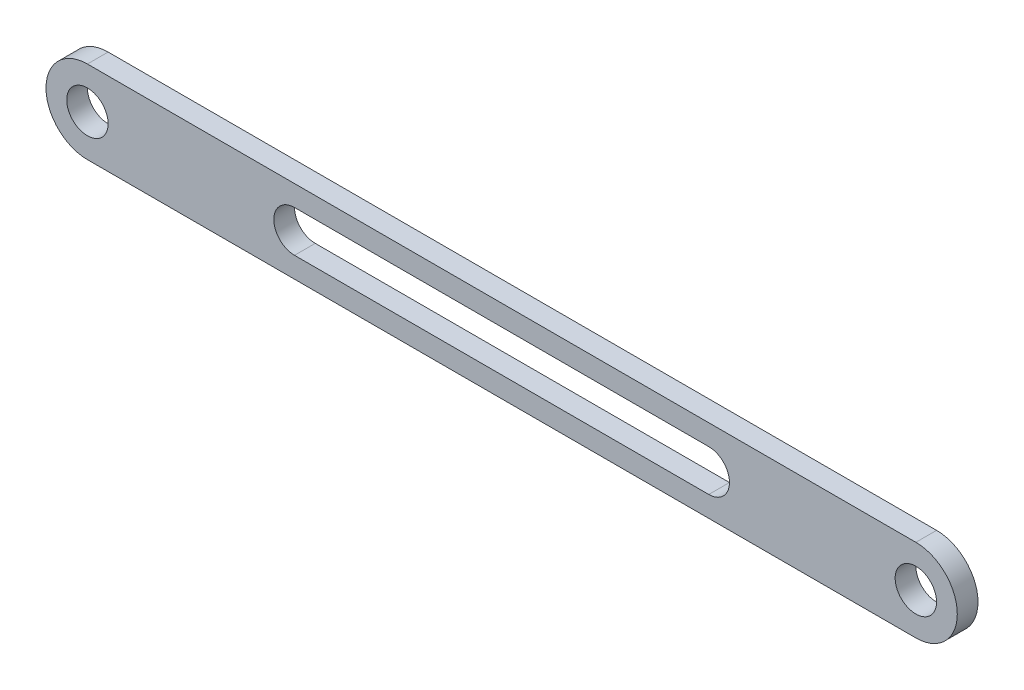
from build123d import *

# Parameters (mm, degrees)
SKETCH1_R           = 10
BOSS_EXTRUDE1_DEPTH = 10


with BuildPart() as part:
    # Sketch1 → Boss-Extrude1 (new body)
    with BuildSketch(Plane.XY):
        with BuildLine():
            Line((-89.519341996, 20), (310.480658004, 20))
            ThreePointArc((310.480658004, 20), (330.480658004, 0), (310.480658004, -20))
            Line((310.480658004, -20), (-89.519341996, -20))
            ThreePointArc((-89.519341996, -20), (-109.519341996, 0), (-89.519341996, 20))
        make_face()
        with Locations((-89.519341996, 0)):
            Circle(SKETCH1_R, mode=Mode.SUBTRACT)
        with Locations((310.480658004, 0)):
            Circle(SKETCH1_R, mode=Mode.SUBTRACT)
        with BuildLine():
            Line((10.480658004, 10), (210.480658004, 10))
            ThreePointArc((210.480658004, 10), (220.480658004, 0), (210.480658004, -10))
            Line((210.480658004, -10), (10.480658004, -10))
            ThreePointArc((10.480658004, -10), (0.480658004, 0), (10.480658004, 10))
        make_face(mode=Mode.SUBTRACT)
    extrude(amount=BOSS_EXTRUDE1_DEPTH)


solid = part.part
